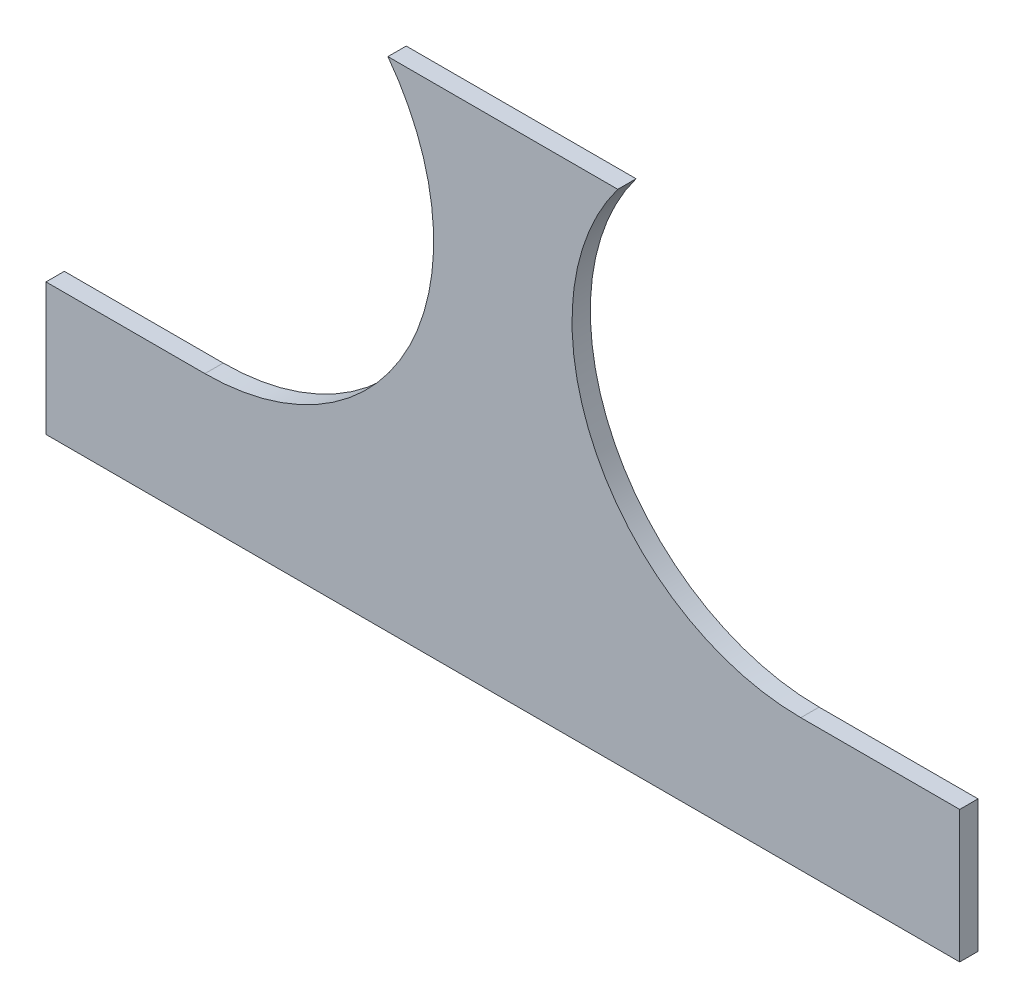
from build123d import *

# Parameters (mm, degrees)
SKETCH1_W           = 249.6
SKETCH1_H           = 267.4
BOSS_EXTRUDE1_DEPTH = 5
SKETCH5_W           = 249.6
SKETCH5_H           = 131.304588604
CUT_EXTRUDE3_DEPTH  = 6


with BuildPart() as part:
    # Sketch1 → Boss-Extrude1 (new body)
    with BuildSketch(Plane.XY):
        with Locations((124.8, -133.7)):
            Rectangle(SKETCH1_W, SKETCH1_H)
    extrude(amount=BOSS_EXTRUDE1_DEPTH)

    # Sketch5 → Cut-Extrude3 (cut, through all)
    with BuildSketch(Plane.XY.offset(5)):
        with Locations((124.8, -201.747705698)):
            Rectangle(SKETCH5_W, SKETCH5_H)
        with BuildLine():
            Line((249.6, 25), (206.197139999, 25))
            ThreePointArc((206.197139999, 25), (143.697139999, -37.5), (206.197139999, -100))
            Line((206.197139999, -100), (249.6, -100))
            Line((249.6, -100), (249.6, 25))
        make_face()
        with BuildLine():
            Line((0, 25), (0, -100))
            Line((0, -100), (43.402860001, -100))
            ThreePointArc((43.402860001, -100), (105.902860001, -37.5), (43.402860001, 25))
            Line((43.402860001, 25), (0, 25))
        make_face()
    extrude(amount=-CUT_EXTRUDE3_DEPTH, mode=Mode.SUBTRACT)


solid = part.part
